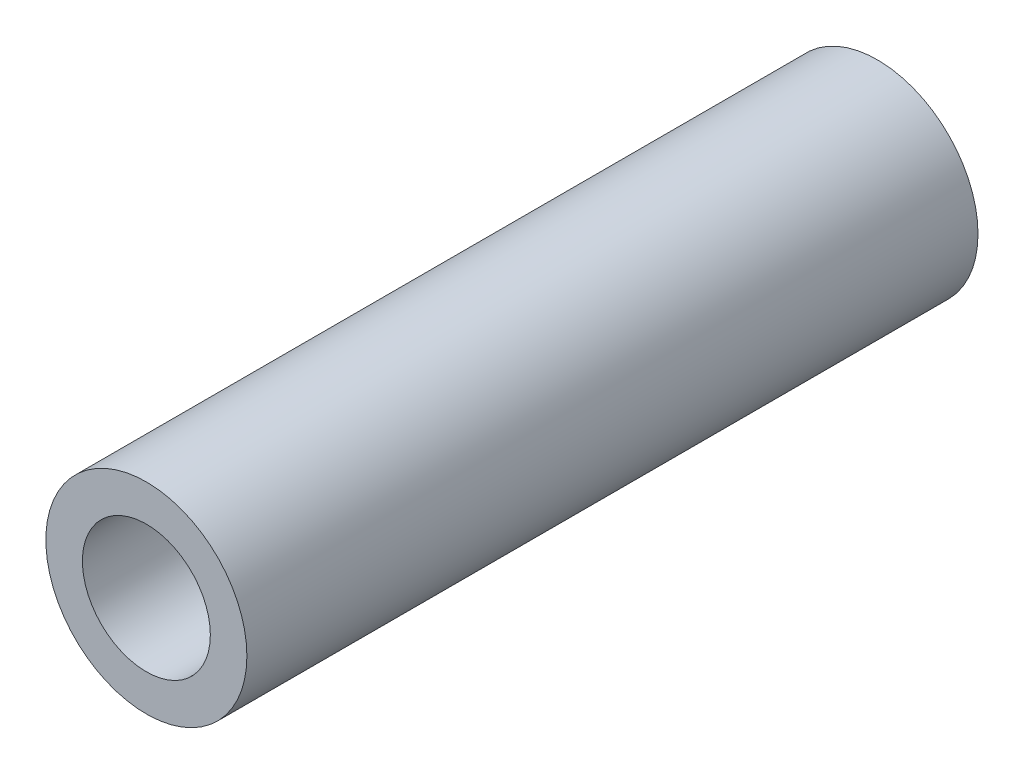
from build123d import *

# Parameters (mm, degrees)
SKETCH1_R           = 2.75
SKETCH1_R_2         = 1.75
BOSS_EXTRUDE1_DEPTH = 20


with BuildPart() as part:
    # Sketch1 → Boss-Extrude1 (new body)
    with BuildSketch(Plane.XY):
        Circle(SKETCH1_R)
        Circle(SKETCH1_R_2, mode=Mode.SUBTRACT)
    extrude(amount=BOSS_EXTRUDE1_DEPTH)


solid = part.part
